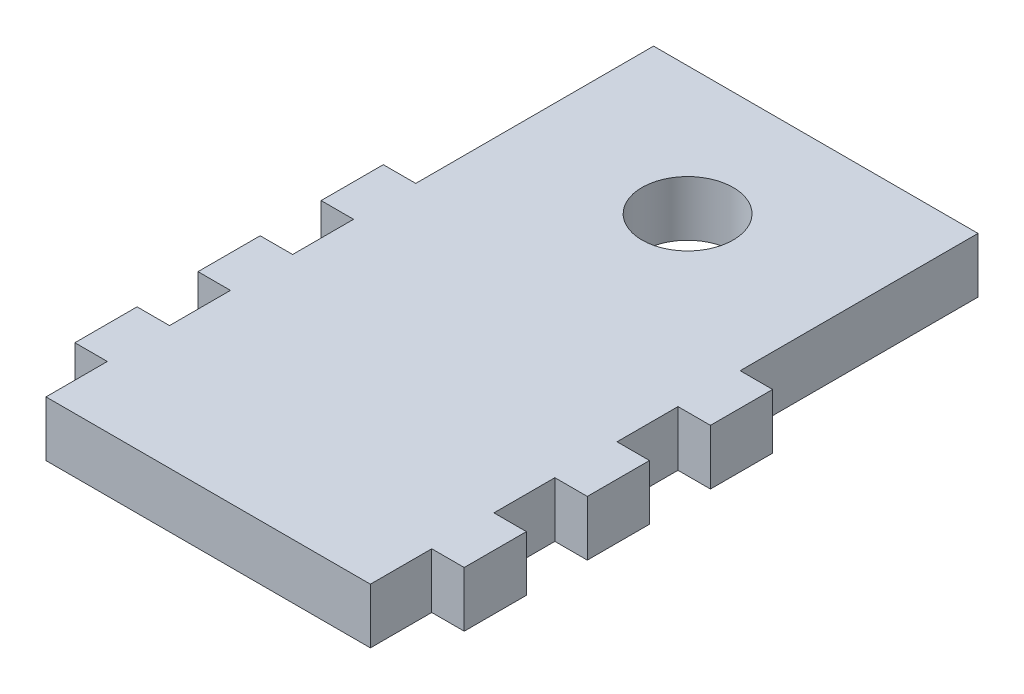
from build123d import *

# Parameters (mm, degrees)
SKETCH1_W           = 31.65
SKETCH1_H           = 59.35
SKETCH1_R           = 4.5
SKETCH1_W_2         = 3.175
SKETCH1_H_2         = 6
BOSS_EXTRUDE1_DEPTH = 5.4
SKETCH2_R           = 4.45936
BOSS_EXTRUDE2_DEPTH = 5.4


with BuildPart() as part:
    # Sketch1 → Boss-Extrude1 (new body)
    with BuildSketch(Plane(origin=(0, 0, 0), x_dir=(1, 0, 0), z_dir=(0, 1, 0))):
        with Locations((-3.498626473, 0.073295681)):
            Rectangle(SKETCH1_W, SKETCH1_H)
        with Locations((-3.498626473, 17.248295681)):
            Circle(SKETCH1_R, mode=Mode.SUBTRACT)
        with Locations((-20.911126473, 3.484009967)):
            Rectangle(SKETCH1_W_2, SKETCH1_H_2)
        with Locations((-20.911126473, -8.558847176)):
            Rectangle(SKETCH1_W_2, SKETCH1_H_2)
        with Locations((-20.911126473, -20.601704319)):
            Rectangle(SKETCH1_W_2, SKETCH1_H_2)
        with Locations((13.913873527, -20.601704319)):
            Rectangle(SKETCH1_W_2, SKETCH1_H_2)
        with Locations((13.913873527, -8.558847176)):
            Rectangle(SKETCH1_W_2, SKETCH1_H_2)
        with Locations((13.913873527, 3.484009967)):
            Rectangle(SKETCH1_W_2, SKETCH1_H_2)
    extrude(amount=BOSS_EXTRUDE1_DEPTH)

    # Sketch2 → Boss-Extrude2 (add)
    with BuildSketch(Plane(origin=(0, 5.4, 0), x_dir=(1, 0, 0), z_dir=(0, 1, 0))):
        Polygon((12.367013527, 6.524649967), (12.367013527, 29.788935681), (-19.364266473, 29.788935681), (-19.364266473, 6.524649967), (-22.539266473, 6.524649967), (-22.539266473, 0.443369967), (-19.364266473, 0.443369967), (-19.364266473, -5.518207176), (-22.539266473, -5.518207176), (-22.539266473, -11.599487176), (-19.364266473, -11.599487176), (-19.364266473, -17.561064319), (-22.539266473, -17.561064319), (-22.539266473, -23.642344319), (-19.364266473, -23.642344319), (-19.364266473, -29.642344319), (12.367013527, -29.642344319), (12.367013527, -23.642344319), (15.542013527, -23.642344319), (15.542013527, -17.561064319), (12.367013527, -17.561064319), (12.367013527, -11.599487176), (15.542013527, -11.599487176), (15.542013527, -5.518207176), (12.367013527, -5.518207176), (12.367013527, 0.443369967), (15.542013527, 0.443369967), (15.542013527, 6.524649967), align=None)
        with Locations((-3.498626473, 17.248295681)):
            Circle(SKETCH2_R, mode=Mode.SUBTRACT)
    extrude(amount=-BOSS_EXTRUDE2_DEPTH)


solid = part.part
